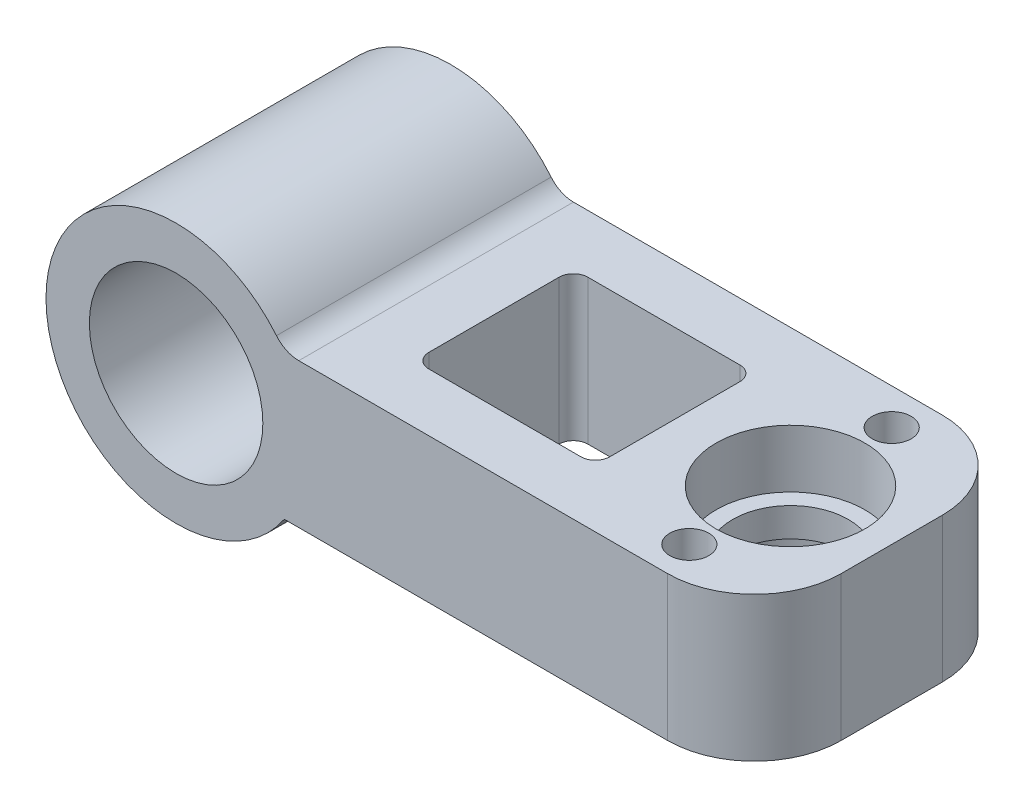
from build123d import *

# Parameters (mm, degrees)
SKETCH1_R                  = 9
SKETCH1_R_2                = 6
MAIN_DEPTH                 = 9.5
SKETCH2_W                  = 40
SKETCH2_H                  = 19
SKETCH2_R                  = 4
SKETCH2_R_2                = 1.35
BALLSUPPORTEXTRUSION_DEPTH = 5
SKETCH3_R                  = 5.15
BALLSUPPORTHOLE_DEPTH      = 4
FILLET2_R                  = 2
SKETCH5_R                  = 6
CUT_EXTRUDE2_DEPTH         = 20
SKETCH6_W                  = 12.514718626
SKETCH6_H                  = 11
CUT_EXTRUDE3_DEPTH         = 15
FILLET3_R                  = 1
FILLET4_R                  = 6


with BuildPart() as part:
    # Sketch1 → Main (new body, symmetric)
    with BuildSketch(Plane.XY):
        Circle(SKETCH1_R)
        Circle(SKETCH1_R_2, mode=Mode.SUBTRACT)
    extrude(amount=MAIN_DEPTH, both=True)

    # Sketch2 → BallSupportExtrusion (add, symmetric)
    with BuildSketch(Plane(origin=(0, 0, 0), x_dir=(1, 0, 0), z_dir=(0, 1, 0))):
        with Locations((20, 0)):
            Rectangle(SKETCH2_W, SKETCH2_H)
        with Locations((33, 0)):
            Circle(SKETCH2_R, mode=Mode.SUBTRACT)
        with Locations((33, 7)):
            Circle(SKETCH2_R_2, mode=Mode.SUBTRACT)
        with Locations((33, -7)):
            Circle(SKETCH2_R_2, mode=Mode.SUBTRACT)
    extrude(amount=BALLSUPPORTEXTRUSION_DEPTH, both=True)

    # Sketch3 → BallSupportHole (cut)
    with BuildSketch(Plane(origin=(0, 5, 0), x_dir=(1, 0, 0), z_dir=(0, 1, 0))):
        with Locations((33, 0)):
            Circle(SKETCH3_R)
    ballsupporthole = extrude(amount=-BALLSUPPORTHOLE_DEPTH, mode=Mode.SUBTRACT)

    # Fillet2
    fillet2_edges = [part.edges().sort_by_distance(p)[0] for p in [
        (7.483314774, 5, 0),
    ]]
    fillet(fillet2_edges, radius=FILLET2_R)

    # Sketch5 → Cut-Extrude2 (cut, through all)
    with BuildSketch(Plane.XY.offset(9.5)):
        Circle(SKETCH5_R)
    extrude(amount=-CUT_EXTRUDE2_DEPTH, mode=Mode.SUBTRACT)

    # Mirror1: BallSupportHole across plane
    add(ballsupporthole.mirror(Plane.ZX), mode=Mode.SUBTRACT)

    # Sketch6 → Cut-Extrude3 (cut, through all)
    with BuildSketch(Plane(origin=(0, 5, 0), x_dir=(1, 0, 0), z_dir=(0, 1, 0))):
        with Locations((18.742640687, 0)):
            Rectangle(SKETCH6_W, SKETCH6_H)
    extrude(amount=-CUT_EXTRUDE3_DEPTH, mode=Mode.SUBTRACT)

    # Fillet3
    fillet3_edges = [part.edges().sort_by_distance(p)[0] for p in [
        (12.485281374, 0, 5.5),
        (12.485281374, 0, -5.5),
        (25, 0, -5.5),
        (25, 0, 5.5),
    ]]
    fillet(fillet3_edges, radius=FILLET3_R)

    # Fillet4
    fillet4_edges = [part.edges().sort_by_distance(p)[0] for p in [
        (40, 0, 9.5),
        (40, 0, -9.5),
    ]]
    fillet(fillet4_edges, radius=FILLET4_R)


solid = part.part
